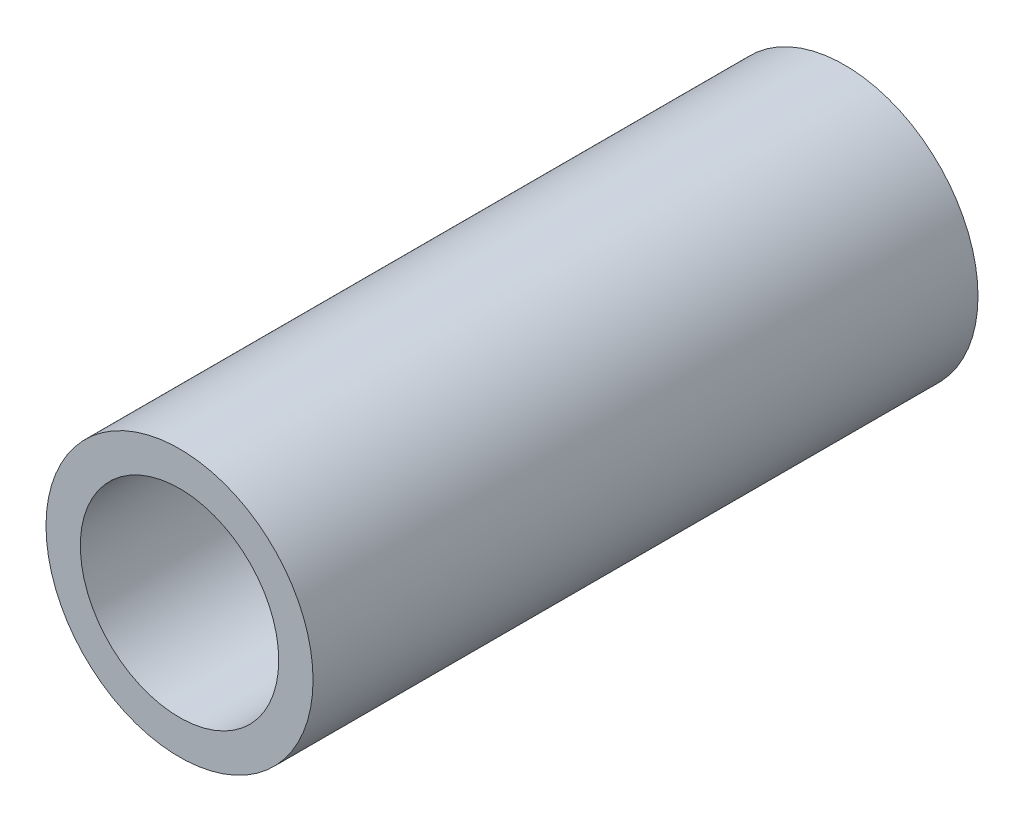
from build123d import *

# Parameters (mm, degrees)
SKETCH1_R      = 3.1877
SKETCH1_R_2    = 2.36855
EXTRUDE1_DEPTH = 7.9375


with BuildPart() as part:
    # Sketch1 → Extrude1 (new body, symmetric)
    with BuildSketch(Plane.XY):
        Circle(SKETCH1_R)
        Circle(SKETCH1_R_2, mode=Mode.SUBTRACT)
    extrude(amount=EXTRUDE1_DEPTH, both=True)


solid = part.part
